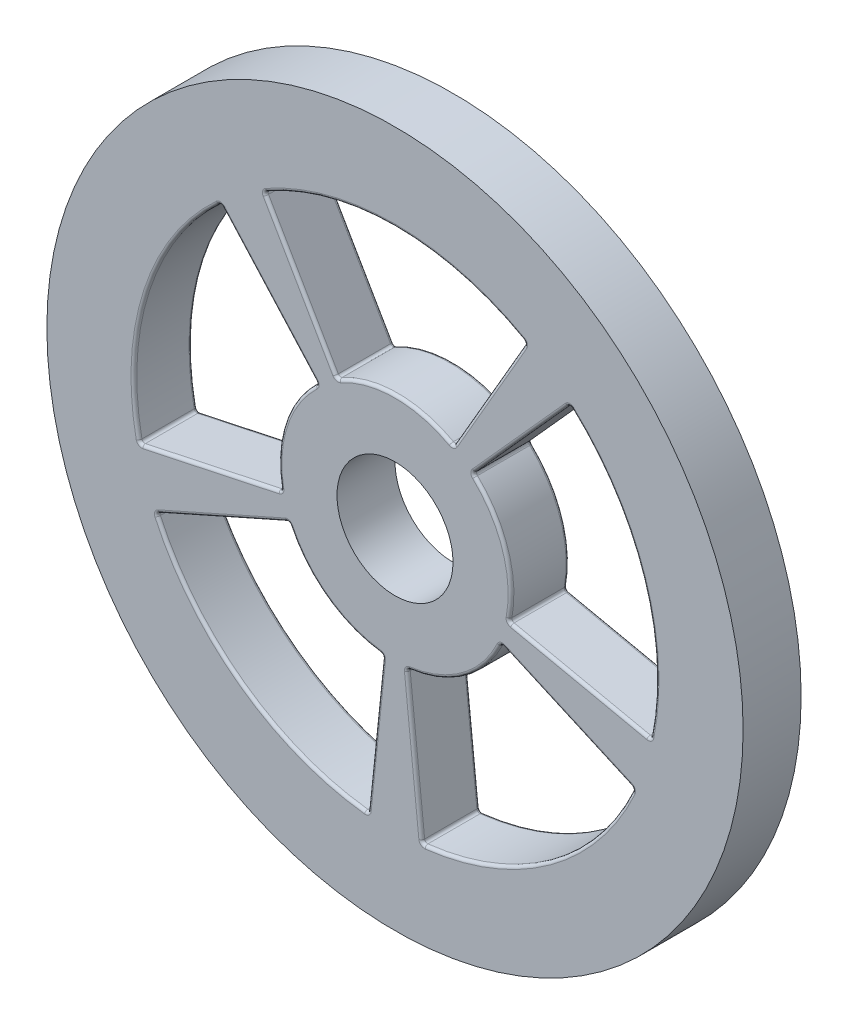
from build123d import *

# Parameters (mm, degrees)
SKETCH1_R           = 60
SKETCH1_R_2         = 10
BOSS_EXTRUDE1_DEPTH = 5
CUT_EXTRUDE1_DEPTH  = 86.440037453
FILLET2_R           = 0.5


with BuildPart() as part:
    # Sketch1 → Boss-Extrude1 (new, symmetric)
    with BuildSketch(Plane.XY):
        Circle(SKETCH1_R)
        Circle(SKETCH1_R_2, mode=Mode.SUBTRACT)
    extrude(amount=BOSS_EXTRUDE1_DEPTH, both=True)

    # Sketch2 → Cut-Extrude1 (cut, through all)
    with BuildSketch(Plane.XY.offset(5)):
        with BuildLine():
            Line((-22.533941443, 38.951527352), (-10.015085086, 17.311789934))
            ThreePointArc((-10.015085086, 17.311789934), (0, 20), (10.015085086, 17.311789934))
            Line((10.015085086, 17.311789934), (22.533941443, 38.951527352))
            ThreePointArc((22.533941443, 38.951527352), (0, 45), (-22.533941443, 38.951527352))
        make_face()
        with BuildLine():
            Line((30.081733051, 33.467735756), (13.369659134, 14.874549225))
            ThreePointArc((13.369659134, 14.874549225), (19.021130326, 6.180339887), (19.559322117, -4.175274639))
            Line((19.559322117, -4.175274639), (44.008474764, -9.394367939))
            ThreePointArc((44.008474764, -9.394367939), (42.797543233, 13.905764747), (30.081733051, 33.467735756))
        make_face()
        with BuildLine():
            Line((41.125474909, -18.267329128), (18.277988849, -8.118812946))
            ThreePointArc((18.277988849, -8.118812946), (11.755705046, -16.180339887), (2.073240779, -19.892251574))
            Line((2.073240779, -19.892251574), (4.664791754, -44.757566041))
            ThreePointArc((4.664791754, -44.757566041), (26.450336353, -36.405764747), (41.125474909, -18.267329128))
        make_face()
        with BuildLine():
            Line((-4.664791754, -44.757566041), (-2.073240779, -19.892251574))
            ThreePointArc((-2.073240779, -19.892251574), (-11.755705046, -16.180339887), (-18.277988849, -8.118812946))
            Line((-18.277988849, -8.118812946), (-41.125474909, -18.267329128))
            ThreePointArc((-41.125474909, -18.267329128), (-26.450336353, -36.405764747), (-4.664791754, -44.757566041))
        make_face()
        with BuildLine():
            Line((-44.008474764, -9.394367939), (-19.559322117, -4.175274639))
            ThreePointArc((-19.559322117, -4.175274639), (-19.021130326, 6.180339887), (-13.369659134, 14.874549225))
            Line((-13.369659134, 14.874549225), (-30.081733051, 33.467735756))
            ThreePointArc((-30.081733051, 33.467735756), (-42.797543233, 13.905764747), (-44.008474764, -9.394367939))
        make_face()
    extrude(amount=-CUT_EXTRUDE1_DEPTH, mode=Mode.SUBTRACT)

    # Fillet2
    fillet2_edges = [part.edges().sort_by_distance(p)[0] for p in [
        (3.369016267, -32.324908807, -5),
        (3.369016267, -32.324908807, 5),
        (29.701731879, -13.193071037, -5),
        (29.701731879, -13.193071037, 5),
        (-29.701731879, -13.193071037, -5),
        (-29.701731879, -13.193071037, 5),
        (-3.369016267, -32.324908807, -5),
        (-3.369016267, -32.324908807, 5),
        (-21.725696093, 24.17114249, -5),
        (-21.725696093, 24.17114249, 5),
        (-31.78389844, -6.784821289, -5),
        (-31.78389844, -6.784821289, 5),
        (16.274513265, 28.131658643, -5),
        (16.274513265, 28.131658643, 5),
        (-16.274513265, 28.131658643, -5),
        (-16.274513265, 28.131658643, 5),
        (31.78389844, -6.784821289, -5),
        (31.78389844, -6.784821289, 5),
        (21.725696093, 24.17114249, -5),
        (21.725696093, 24.17114249, 5),
        (-2.073240779, -19.892251574, 0),
        (-11.755705046, -16.180339887, -5),
        (-18.277988849, -8.118812946, 0),
        (-11.755705046, -16.180339887, 5),
        (-19.559322117, -4.175274639, 0),
        (-19.021130326, 6.180339887, -5),
        (-13.369659134, 14.874549225, 0),
        (-19.021130326, 6.180339887, 5),
        (-10.015085086, 17.311789934, 0),
        (0, 20, -5),
        (10.015085086, 17.311789934, 0),
        (0, 20, 5),
        (13.369659134, 14.874549225, 0),
        (19.021130326, 6.180339887, -5),
        (19.559322117, -4.175274639, 0),
        (19.021130326, 6.180339887, 5),
        (18.277988849, -8.118812946, 0),
        (11.755705046, -16.180339887, -5),
        (2.073240779, -19.892251574, 0),
        (11.755705046, -16.180339887, 5),
        (4.664791754, -44.757566041, 0),
        (26.450336353, -36.405764747, -5),
        (41.125474909, -18.267329128, 0),
        (26.450336353, -36.405764747, 5),
        (-41.125474909, -18.267329128, 0),
        (-26.450336353, -36.405764747, -5),
        (-4.664791754, -44.757566041, 0),
        (-26.450336353, -36.405764747, 5),
        (-30.081733051, 33.467735756, 0),
        (-42.797543233, 13.905764747, -5),
        (-44.008474764, -9.394367939, 0),
        (-42.797543233, 13.905764747, 5),
        (22.533941443, 38.951527352, 0),
        (0, 45, -5),
        (-22.533941443, 38.951527352, 0),
        (0, 45, 5),
        (44.008474764, -9.394367939, 0),
        (42.797543233, 13.905764747, -5),
        (30.081733051, 33.467735756, 0),
        (42.797543233, 13.905764747, 5),
    ]]
    fillet(fillet2_edges, radius=FILLET2_R)


solid = part.part
